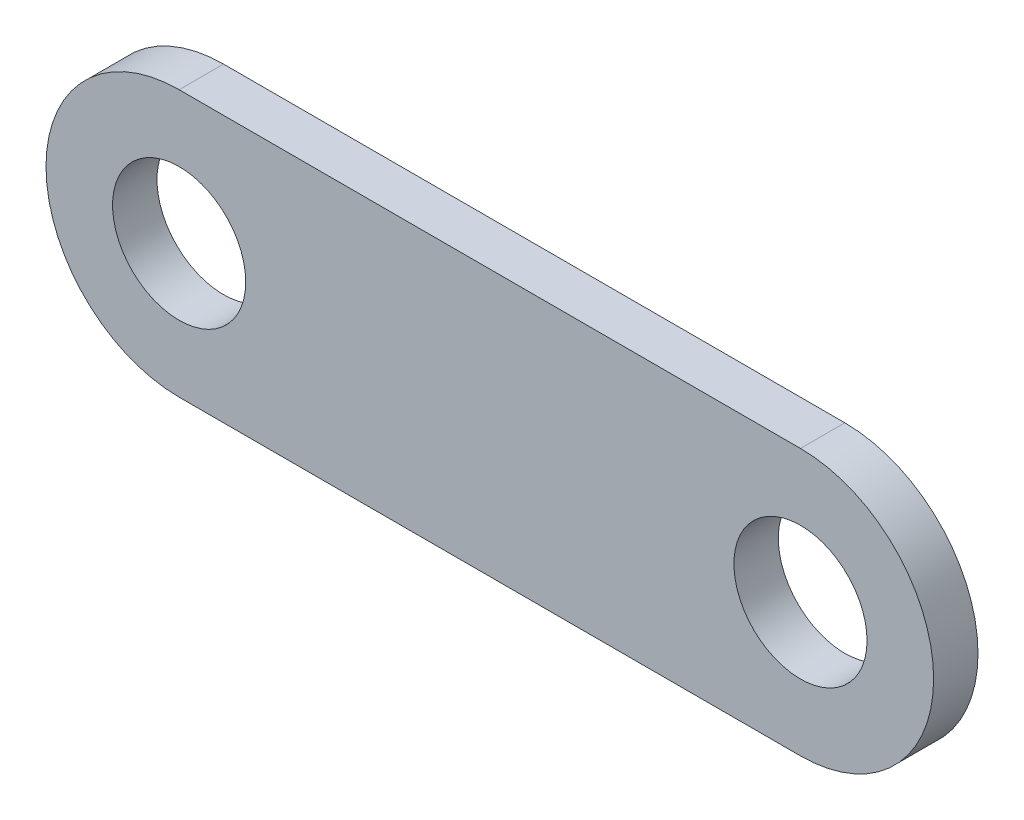
from build123d import *

# Parameters (mm, degrees)
SKETCH1_R           = 4.7625
BOSS_EXTRUDE1_DEPTH = 3.175


with BuildPart() as part:
    # Sketch1 → Boss-Extrude1 (new body)
    with BuildSketch(Plane.XY):
        with BuildLine():
            Line((0, -9.525), (-44.45, -9.525))
            ThreePointArc((-44.45, -9.525), (-53.975, 0), (-44.45, 9.525))
            Line((-44.45, 9.525), (0, 9.525))
            ThreePointArc((0, 9.525), (9.525, 0), (0, -9.525))
        make_face()
        with Locations((-44.45, 0)):
            Circle(SKETCH1_R, mode=Mode.SUBTRACT)
        Circle(SKETCH1_R, mode=Mode.SUBTRACT)
    extrude(amount=-BOSS_EXTRUDE1_DEPTH)


solid = part.part
